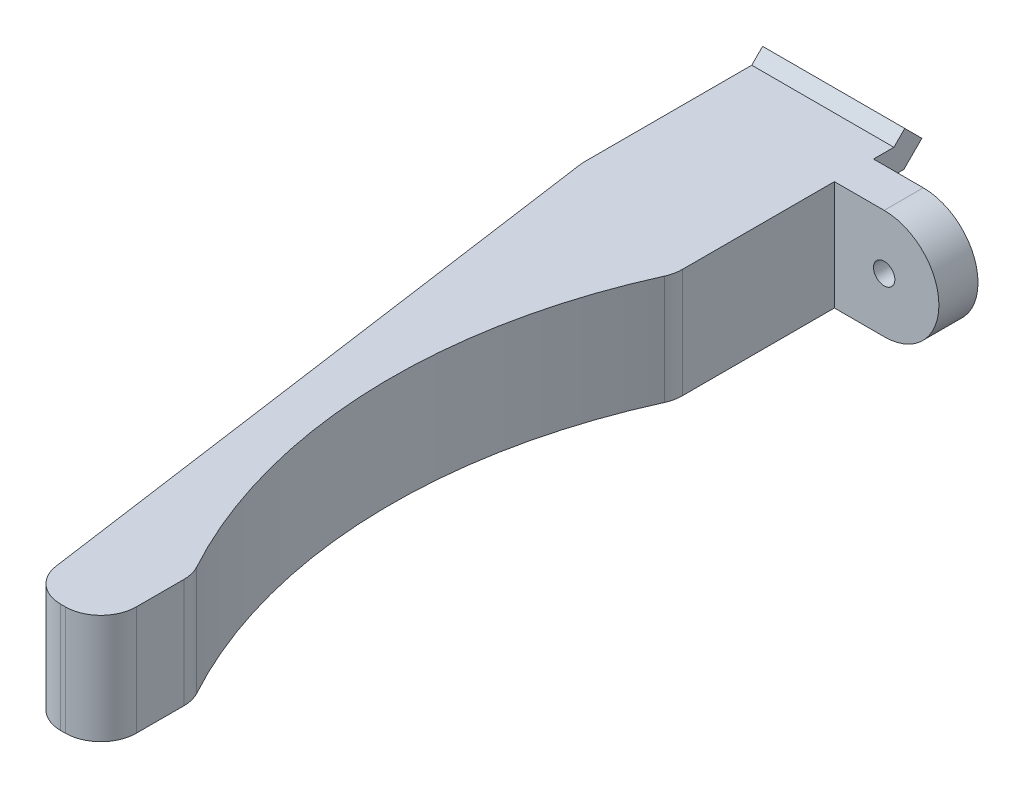
from build123d import *

# Parameters (mm, degrees)
SKETCH2_W           = 10
SKETCH2_H           = 14.768412439
BOSS_EXTRUDE1_DEPTH = 5
BOSS_EXTRUDE4_DEPTH = 10
SKETCH9_W           = 10
SKETCH9_H           = 3.18
SKETCH9_H_2         = 3.888412439
CUT_EXTRUDE3_DEPTH  = 5
BOSS_EXTRUDE5_DEPTH = 7.7
SKETCH12_R          = 0.75
BOSS_EXTRUDE7_DEPTH = 2.75
FILLET1_R           = 2.5


with BuildPart() as part:
    # Sketch2 → Boss-Extrude1 (new body)
    with BuildSketch(Plane.XY):
        with Locations((0, 1.566049366)):
            Rectangle(SKETCH2_W, SKETCH2_H)
    extrude(amount=BOSS_EXTRUDE1_DEPTH)

    # Sketch8 → Boss-Extrude4 (add)
    with BuildSketch(Plane.ZY.offset(5)):
        Polygon((-0.15, 5.770255585), (0, 5.770255585), (0, 4.070255585), (-0.15, 4.070255585), (-2.137867966, 4.070255585), (-3.402081528, 5.334469147), (-2.2, 6.536550675), (-1.43370491, 5.770255585), align=None)
        Polygon((-0.15, -1.929744415), (0, -1.929744415), (0, -0.229744415), (-0.15, -0.229744415), (-1.43370491, -0.229744415), (-2.2, 0.536550675), (-3.402081528, -0.665530853), (-2.137867966, -1.929744415), align=None)
    extrude(amount=-BOSS_EXTRUDE4_DEPTH)

    # Sketch9 → Cut-Extrude3 (cut)
    with BuildSketch(Plane(origin=(0, 0, 0), x_dir=(-1, 0, 0), z_dir=(0, 0, -1))):
        with Locations((0, 7.360255585)):
            Rectangle(SKETCH9_W, SKETCH9_H)
        with Locations((0, -3.873950635)):
            Rectangle(SKETCH9_W, SKETCH9_H_2)
    extrude(amount=-CUT_EXTRUDE3_DEPTH, mode=Mode.SUBTRACT)

    # Sketch10 → Boss-Extrude5 (add)
    with BuildSketch(Plane(origin=(0, 5.770255585, 0), x_dir=(1, 0, 0), z_dir=(0, 1, 0))):
        with BuildLine():
            Line((-5, -5), (-5, -10.5))
            Line((-5, -10.5), (1.352445729, -55.7))
            Line((1.352445729, -55.7), (6.352445729, -55.7))
            Line((6.352445729, -55.7), (6.352445729, -49.2))
            ThreePointArc((6.352445729, -49.2), (1.383429579, -31.764936646), (5, -14))
            Line((5, -14), (5, -5))
            Line((5, -5), (-5, -5))
        make_face()
    extrude(amount=-BOSS_EXTRUDE5_DEPTH)

    # Sketch12 → Boss-Extrude7 (add)
    with BuildSketch(Plane.XY):
        with BuildLine():
            Line((5, 5.770255585), (8.5, 5.770255585))
            ThreePointArc((8.5, 5.770255585), (12.35, 1.920255585), (8.5, -1.929744415))
            Line((8.5, -1.929744415), (5, -1.929744415))
            Line((5, -1.929744415), (5, 5.770255585))
        make_face()
        with Locations((8.5, 1.920255585)):
            Circle(SKETCH12_R, mode=Mode.SUBTRACT)
    extrude(amount=BOSS_EXTRUDE7_DEPTH)

    # Fillet1
    fillet1_edges = [part.edges().sort_by_distance(p)[0] for p in [
        (6.352445729, 1.920255585, 49.2),
        (5, 1.920255585, 14),
        (1.352445729, 1.920255585, 55.7),
        (6.352445729, 1.920255585, 55.7),
    ]]
    fillet(fillet1_edges, radius=FILLET1_R)


solid = part.part
